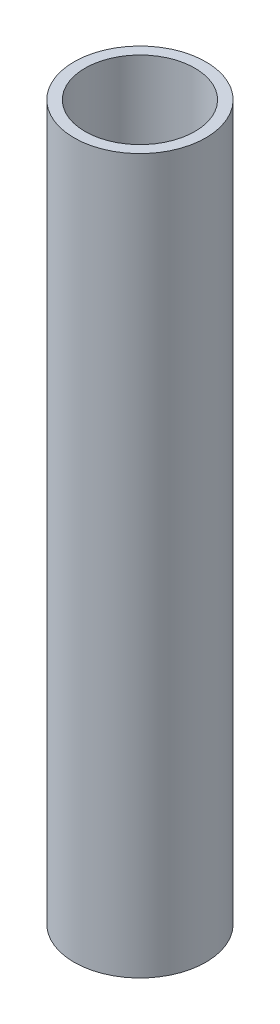
from build123d import *

# Parameters (mm, degrees)
SKETCH1_R           = 3
SKETCH1_R_2         = 2.5
BOSS_EXTRUDE1_DEPTH = 32.5


with BuildPart() as part:
    # Sketch1 → Boss-Extrude1 (new body)
    with BuildSketch(Plane(origin=(0, 0, 0), x_dir=(1, 0, 0), z_dir=(0, 1, 0))):
        Circle(SKETCH1_R)
        Circle(SKETCH1_R_2, mode=Mode.SUBTRACT)
    extrude(amount=BOSS_EXTRUDE1_DEPTH)


solid = part.part
